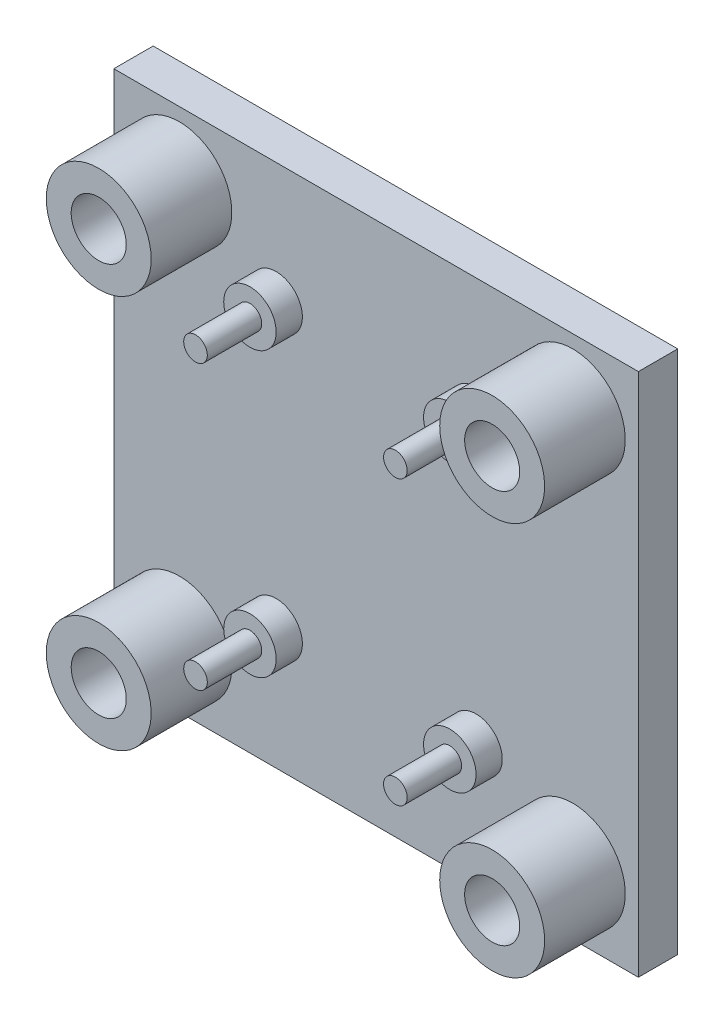
from build123d import *

# Parameters (mm, degrees)
SKETCH_1_W          = 40
SKETCH_1_H          = 40
EXTRUDE_1_DEPTH     = 3
SKETCH_2_R          = 2
EXTRUDE_2_DEPTH     = 2
SKETCH_3_R          = 0.9
EXTRUDE_3_DEPTH     = 4.15
SKETCH_4_R          = 4
EXTRUDE_4_DEPTH     = 6.15
SKETCH_5_R          = 2.1
CUT_EXTRUDE_1_DEPTH = 10.15


with BuildPart() as part:
    # 草圖1 → 填料-伸長1 (new body)
    with BuildSketch(Plane.XY):
        Rectangle(SKETCH_1_W, SKETCH_1_H)
    extrude(amount=EXTRUDE_1_DEPTH)

    # 草圖2 → 填料-伸長2 (add)
    with BuildSketch(Plane.XY.offset(3)):
        with Locations((-7.62, 10.795)):
            Circle(SKETCH_2_R)
        with Locations((-7.62, -10.795)):
            Circle(SKETCH_2_R)
        with Locations((7.62, 10.795)):
            Circle(SKETCH_2_R)
        with Locations((7.62, -10.795)):
            Circle(SKETCH_2_R)
    extrude(amount=EXTRUDE_2_DEPTH)

    # 草圖3 → 填料-伸長3 (add)
    with BuildSketch(Plane.XY.offset(5)):
        with Locations((-7.62, 10.795)):
            Circle(SKETCH_3_R)
        with Locations((-7.62, -10.795)):
            Circle(SKETCH_3_R)
        with Locations((7.62, -10.795)):
            Circle(SKETCH_3_R)
        with Locations((7.62, 10.795)):
            Circle(SKETCH_3_R)
    extrude(amount=EXTRUDE_3_DEPTH)

    # 草圖4 → 填料-伸長4 (add)
    with BuildSketch(Plane.XY.offset(3)):
        with Locations((-15, 15)):
            Circle(SKETCH_4_R)
        with Locations((-15, -15)):
            Circle(SKETCH_4_R)
        with Locations((15, -15)):
            Circle(SKETCH_4_R)
        with Locations((15, 15)):
            Circle(SKETCH_4_R)
    extrude(amount=EXTRUDE_4_DEPTH)

    # 草圖5 → 除料-伸長1 (cut, through all)
    with BuildSketch(Plane.XY.offset(9.15)):
        with Locations((-15, 15)):
            Circle(SKETCH_5_R)
        with Locations((-15, -15)):
            Circle(SKETCH_5_R)
        with Locations((15, -15)):
            Circle(SKETCH_5_R)
        with Locations((15, 15)):
            Circle(SKETCH_5_R)
    extrude(amount=-CUT_EXTRUDE_1_DEPTH, mode=Mode.SUBTRACT)


solid = part.part
